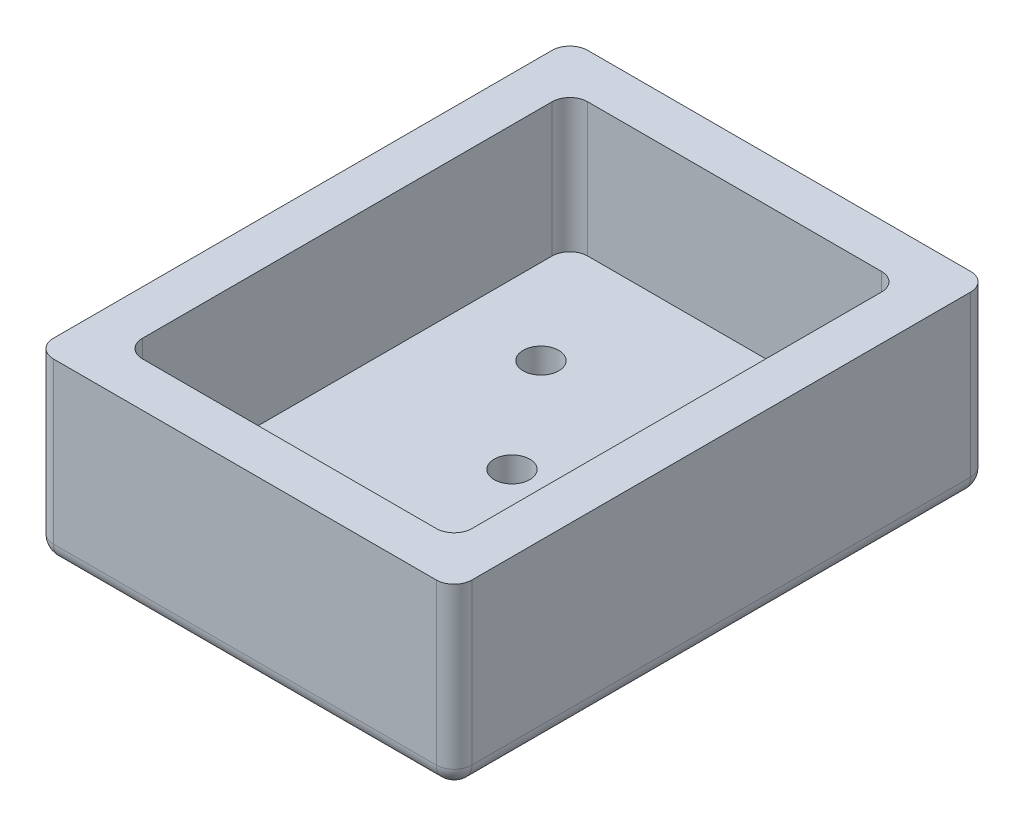
from build123d import *

# Parameters (mm, degrees)
SKETCH1_W           = 47
SKETCH1_H           = 60
BOSS_EXTRUDE1_DEPTH = 20
SHELL1_T            = -5
FILLET2_R           = 2
FILLET3_R           = 2
FILLET4_R           = 2
FILLET5_R           = 2
FILLET6_R           = 2
FILLET7_R           = 2
FILLET8_R           = 2
FILLET9_R           = 2
FILLET10_R          = 2
SKETCH2_R           = 2
CUT_EXTRUDE1_DEPTH  = 10


with BuildPart() as part:
    # Sketch1 → Boss-Extrude1 (new body)
    with BuildSketch(Plane(origin=(0, 0, 0), x_dir=(1, 0, 0), z_dir=(0, 1, 0))):
        with Locations((2.676470588, -4.572192513)):
            Rectangle(SKETCH1_W, SKETCH1_H)
    extrude(amount=BOSS_EXTRUDE1_DEPTH)

    # Shell1
    shell1_openings = [part.faces().sort_by_distance(p)[0] for p in [
        (2.676470588, 20, 4.572192513),
    ]]
    offset(amount=SHELL1_T, openings=shell1_openings, kind=Kind.INTERSECTION)

    # Fillet2
    fillet2_edges = [part.edges().sort_by_distance(p)[0] for p in [
        (21.176470588, 12.5, 29.572192513),
    ]]
    fillet(fillet2_edges, radius=FILLET2_R)

    # Fillet3
    fillet3_edges = [part.edges().sort_by_distance(p)[0] for p in [
        (-15.823529412, 12.5, 29.572192513),
    ]]
    fillet(fillet3_edges, radius=FILLET3_R)

    # Fillet4
    fillet4_edges = [part.edges().sort_by_distance(p)[0] for p in [
        (-15.823529412, 12.5, -20.427807487),
    ]]
    fillet(fillet4_edges, radius=FILLET4_R)

    # Fillet5
    fillet5_edges = [part.edges().sort_by_distance(p)[0] for p in [
        (21.176470588, 12.5, -20.427807487),
    ]]
    fillet(fillet5_edges, radius=FILLET5_R)

    # Fillet6
    fillet6_edges = [part.edges().sort_by_distance(p)[0] for p in [
        (-20.823529412, 10, 34.572192513),
    ]]
    fillet(fillet6_edges, radius=FILLET6_R)

    # Fillet7
    fillet7_edges = [part.edges().sort_by_distance(p)[0] for p in [
        (26.176470588, 10, 34.572192513),
    ]]
    fillet(fillet7_edges, radius=FILLET7_R)

    # Fillet8
    fillet8_edges = [part.edges().sort_by_distance(p)[0] for p in [
        (-20.823529412, 10, -25.427807487),
    ]]
    fillet(fillet8_edges, radius=FILLET8_R)

    # Fillet9
    fillet9_edges = [part.edges().sort_by_distance(p)[0] for p in [
        (26.176470588, 10, -25.427807487),
    ]]
    fillet(fillet9_edges, radius=FILLET9_R)

    # Fillet10
    fillet10_edges = [part.edges().sort_by_distance(p)[0] for p in [
        (2.676470588, 0, 34.572192513),
        (26.176470588, 0, 4.572192513),
        (-20.823529412, 0, 4.572192513),
        (2.676470588, 0, -25.427807487),
    ]]
    fillet(fillet10_edges, radius=FILLET10_R)

    # Sketch2 → Cut-Extrude1 (cut)
    with BuildSketch(Plane(origin=(0, 0, 0), x_dir=(1, 0, 0), z_dir=(0, 1, 0))):
        with Locations((-6.280636193, 7.634914268)):
            Circle(SKETCH2_R)
        with Locations((2.676470588, -4.572192513)):
            Circle(SKETCH2_R)
        with Locations((11.633577369, -16.779299295)):
            Circle(SKETCH2_R)
    extrude(amount=CUT_EXTRUDE1_DEPTH, mode=Mode.SUBTRACT)


solid = part.part
